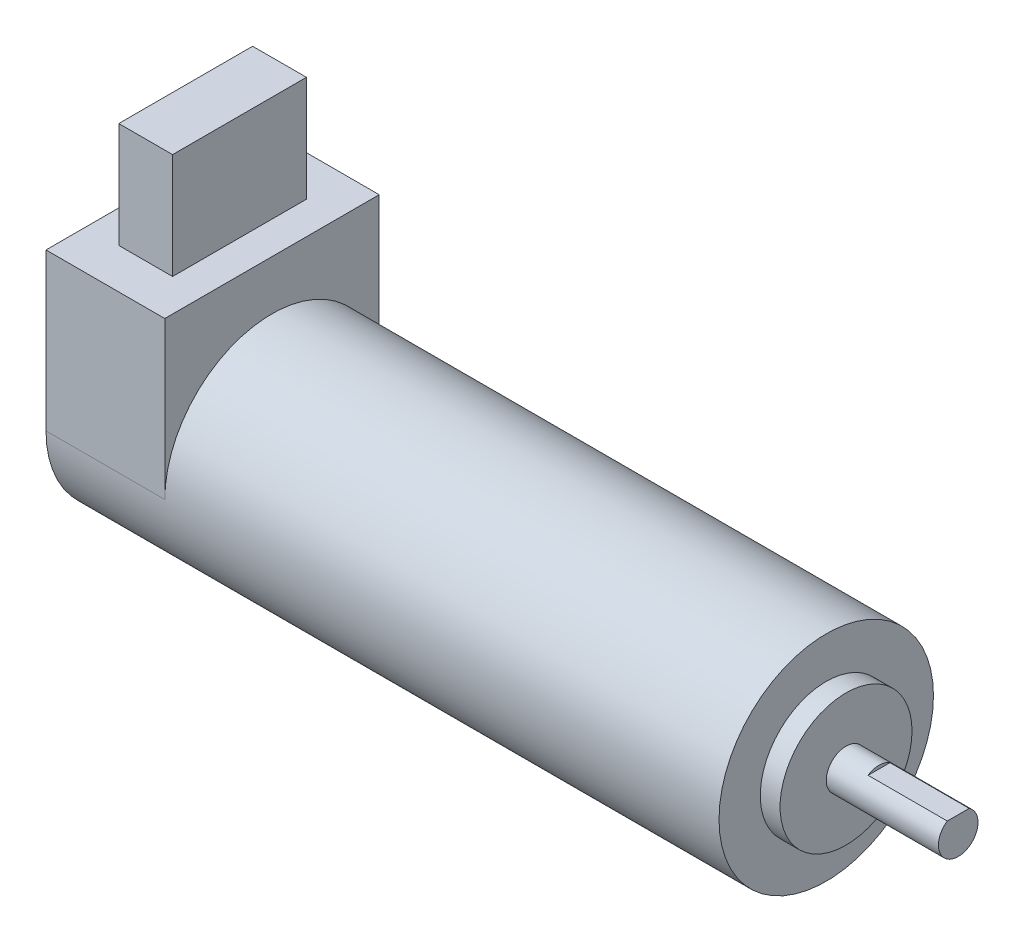
from build123d import *

# Parameters (mm, degrees)
SKETCH1_R           = 16.25
BOSS_EXTRUDE1_DEPTH = 84
SKETCH2_R           = 10
BOSS_EXTRUDE2_DEPTH = 3
SKETCH3_R           = 3
BOSS_EXTRUDE3_DEPTH = 17
CUT_EXTRUDE1_DEPTH  = 12
SKETCH5_R           = 16.25
BOSS_EXTRUDE4_DEPTH = 18
SKETCH6_W           = 8.15482979
SKETCH6_H           = 20.288083416
BOSS_EXTRUDE5_DEPTH = 16


with BuildPart() as part:
    # Sketch1 → Boss-Extrude1 (new body)
    with BuildSketch(Plane(origin=(0, 0, 0), x_dir=(0, 0, -1), z_dir=(1, 0, 0))):
        Circle(SKETCH1_R)
    extrude(amount=BOSS_EXTRUDE1_DEPTH)

    # Sketch2 → Boss-Extrude2 (add)
    with BuildSketch(Plane(origin=(84, 0, 0), x_dir=(0, 0, -1), z_dir=(1, 0, 0))):
        Circle(SKETCH2_R)
    extrude(amount=BOSS_EXTRUDE2_DEPTH)

    # Sketch3 → Boss-Extrude3 (add)
    with BuildSketch(Plane(origin=(87, 0, 0), x_dir=(0, 0, -1), z_dir=(1, 0, 0))):
        Circle(SKETCH3_R)
    extrude(amount=BOSS_EXTRUDE3_DEPTH)

    # Sketch4 → Cut-Extrude1 (cut)
    with BuildSketch(Plane(origin=(104, 0, 0), x_dir=(0, 0, -1), z_dir=(1, 0, 0))):
        Polygon((-63.514658307, 2.5), (-1.658312395, 2.5), (1.658312395, 2.5), (63.514658307, 2.5), (63.514658307, 126.212691825), (-63.514658307, 126.212691825), align=None)
    extrude(amount=-CUT_EXTRUDE1_DEPTH, mode=Mode.SUBTRACT)

    # Sketch5 → Boss-Extrude4 (add)
    with BuildSketch(Plane.ZY):
        Circle(SKETCH5_R)
        with BuildLine():
            Line((-16.25, 23.75), (-16.25, 0))
            ThreePointArc((-16.25, 0), (0, 16.25), (16.25, 0))
            Line((16.25, 0), (16.25, 23.75))
            Line((16.25, 23.75), (-16.25, 23.75))
        make_face()
    extrude(amount=BOSS_EXTRUDE4_DEPTH)

    # Sketch6 → Boss-Extrude5 (add)
    with BuildSketch(Plane(origin=(0, 23.75, 0), x_dir=(1, 0, 0), z_dir=(0, 1, 0))):
        with Locations((-9, 0)):
            Rectangle(SKETCH6_W, SKETCH6_H)
    extrude(amount=BOSS_EXTRUDE5_DEPTH)


solid = part.part
